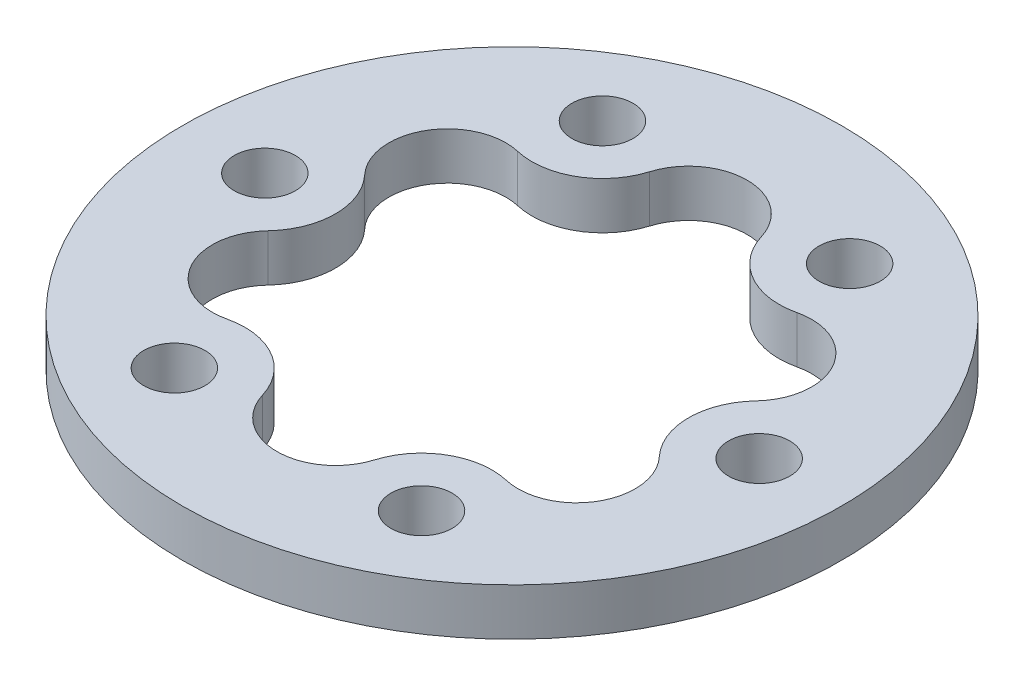
from build123d import *

# Parameters (mm, degrees)
SKETCH_1_R               = 28
SKETCH_1_R_2             = 2.6
EXTRUDE_1_DEPTH          = 4
CUT_EXTRUDE_2_DEPTH      = 1
CUT_EXTRUDE_2_DEPTH_BACK = 5


with BuildPart() as part:
    # 草图1 → 凸台-拉伸1 (new body)
    with BuildSketch(Plane(origin=(0, 0, 0), x_dir=(1, 0, 0), z_dir=(0, 1, 0))):
        Circle(SKETCH_1_R)
        with Locations((10.5, 18.186533479)):
            Circle(SKETCH_1_R_2, mode=Mode.SUBTRACT)
        with Locations((21, 0)):
            Circle(SKETCH_1_R_2, mode=Mode.SUBTRACT)
        with Locations((10.5, -18.186533479)):
            Circle(SKETCH_1_R_2, mode=Mode.SUBTRACT)
        with Locations((-10.5, -18.186533479)):
            Circle(SKETCH_1_R_2, mode=Mode.SUBTRACT)
        with Locations((-21, 0)):
            Circle(SKETCH_1_R_2, mode=Mode.SUBTRACT)
        with Locations((-10.5, 18.186533479)):
            Circle(SKETCH_1_R_2, mode=Mode.SUBTRACT)
    extrude(amount=EXTRUDE_1_DEPTH)

    # 草图4 → 切除-拉伸2 (cut, two sides)
    with BuildSketch(Plane(origin=(0, 4, 0), x_dir=(1, 0, 0), z_dir=(0, 1, 0))) as cut_extrude_2_sk:
        with BuildLine():
            ThreePointArc((4.758569662, 16.444127766), (7.4999998, 12.990381172), (11.861747108, 12.343105991))
            ThreePointArc((11.861747108, 12.343105991), (17.29701741, 9.986437924), (16.620317219, 4.10102167))
            ThreePointArc((16.620317219, 4.10102167), (15, 2.31e-07), (16.620316904, -4.101021333))
            ThreePointArc((16.620316904, -4.101021333), (17.297017641, -9.986437525), (11.861747557, -12.343106096))
            ThreePointArc((11.861747557, -12.343106096), (7.5000002, -12.990380941), (4.758569796, -16.444127324))
            ThreePointArc((4.758569796, -16.444127324), (2.31e-07, -19.972875449), (-4.758569662, -16.444127766))
            ThreePointArc((-4.758569662, -16.444127766), (-7.4999998, -12.990381172), (-11.861747108, -12.343105991))
            ThreePointArc((-11.861747108, -12.343105991), (-17.29701741, -9.986437924), (-16.620317219, -4.10102167))
            ThreePointArc((-16.620317219, -4.10102167), (-15, -2.31e-07), (-16.620316904, 4.101021333))
            ThreePointArc((-16.620316904, 4.101021333), (-17.297017641, 9.986437525), (-11.861747557, 12.343106096))
            ThreePointArc((-11.861747557, 12.343106096), (-7.5000002, 12.990380941), (-4.758569796, 16.444127324))
            ThreePointArc((-4.758569796, 16.444127324), (-2.31e-07, 19.972875449), (4.758569662, 16.444127766))
        make_face()
    extrude(amount=CUT_EXTRUDE_2_DEPTH, mode=Mode.SUBTRACT)
    extrude(cut_extrude_2_sk.sketch, amount=-CUT_EXTRUDE_2_DEPTH_BACK, mode=Mode.SUBTRACT)


solid = part.part
